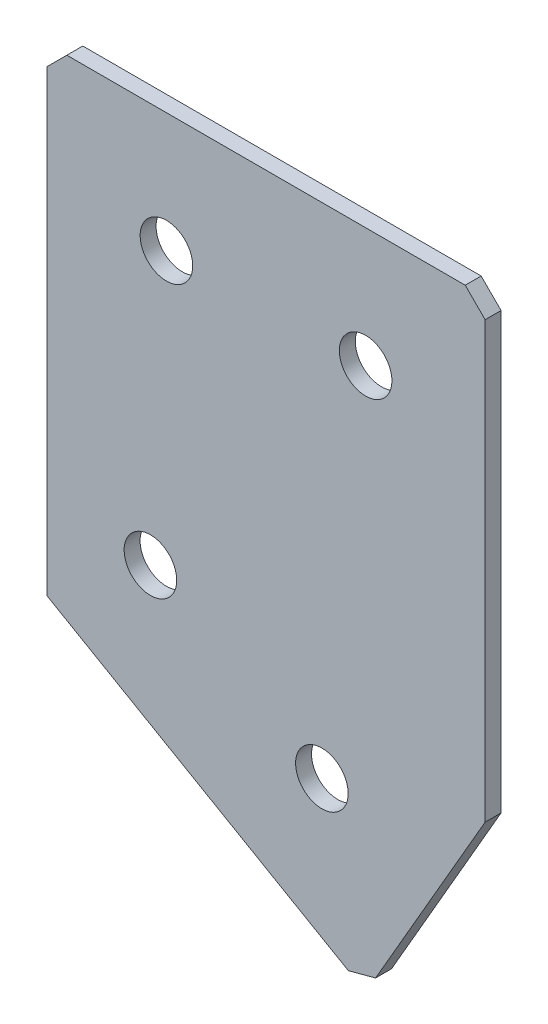
from build123d import *

# Parameters (mm, degrees)
EXTRUDE_1_DEPTH   = 2
HOLE_WIZARD_M61_D = 6.6
CHAMFER_1_SIZE    = 2.5


with BuildPart() as part:
    # Эскиз3 → Бобышка-Вытянуть1 (new body)
    with BuildSketch(Plane(origin=(0, 0, 0), x_dir=(1, 0, 0), z_dir=(0, 0, -1))):
        Polygon((0, 0), (55, 0), (55, 57.113248654), (40, 83.094010768), (0, 60), align=None)
    extrude(amount=EXTRUDE_1_DEPTH)

    # Отверстие с зазором M61 (through all)
    with Locations(Plane(origin=(0, 0, -2), x_dir=(1, 0, 0), z_dir=(0, 0, -1))):
        with Locations((15, 15), (40, 15), (12.990381057, 50.179491924), (34.509618943, 62.603629711)):
            Hole(HOLE_WIZARD_M61_D / 2)

    # Фаска1
    chamfer_1_edges = [part.edges().sort_by_distance(p)[0] for p in [
        (40, -83.094010768, -1),
        (55, 0, -1),
        (0, 0, -1),
    ]]
    chamfer(chamfer_1_edges, length=CHAMFER_1_SIZE)


solid = part.part
